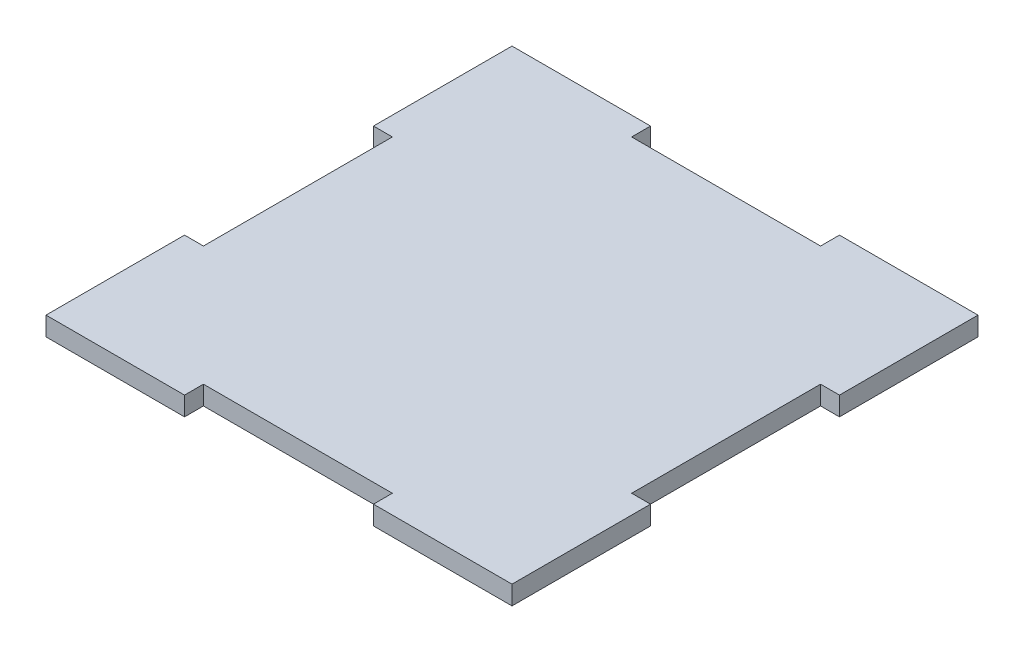
from build123d import *

# Parameters (mm, degrees)
ESBO_O1_W                = 74
ESBO_O1_H                = 74
RESSALTO_EXTRUS_O1_DEPTH = 3
ESBO_O2_W                = 30
ESBO_O2_H                = 3
ESBO_O2_W_2              = 3
ESBO_O2_H_2              = 30
CORTE_EXTRUS_O1_DEPTH    = 3


with BuildPart() as part:
    # Esboço1 → Ressalto-extrusão1 (new body)
    with BuildSketch(Plane(origin=(0, 0, 0), x_dir=(1, 0, 0), z_dir=(0, 1, 0))):
        Rectangle(ESBO_O1_W, ESBO_O1_H)
    extrude(amount=RESSALTO_EXTRUS_O1_DEPTH)

    # Esboço2 → Corte-extrusão1 (cut)
    with BuildSketch(Plane(origin=(0, 3, 0), x_dir=(1, 0, 0), z_dir=(0, 1, 0))):
        with Locations((0, 35.5)):
            Rectangle(ESBO_O2_W, ESBO_O2_H)
        with Locations((35.5, 0)):
            Rectangle(ESBO_O2_W_2, ESBO_O2_H_2)
        with Locations((0, -35.5)):
            Rectangle(ESBO_O2_W, ESBO_O2_H)
        with Locations((-35.5, 0)):
            Rectangle(ESBO_O2_W_2, ESBO_O2_H_2)
    extrude(amount=-CORTE_EXTRUS_O1_DEPTH, mode=Mode.SUBTRACT)


solid = part.part
